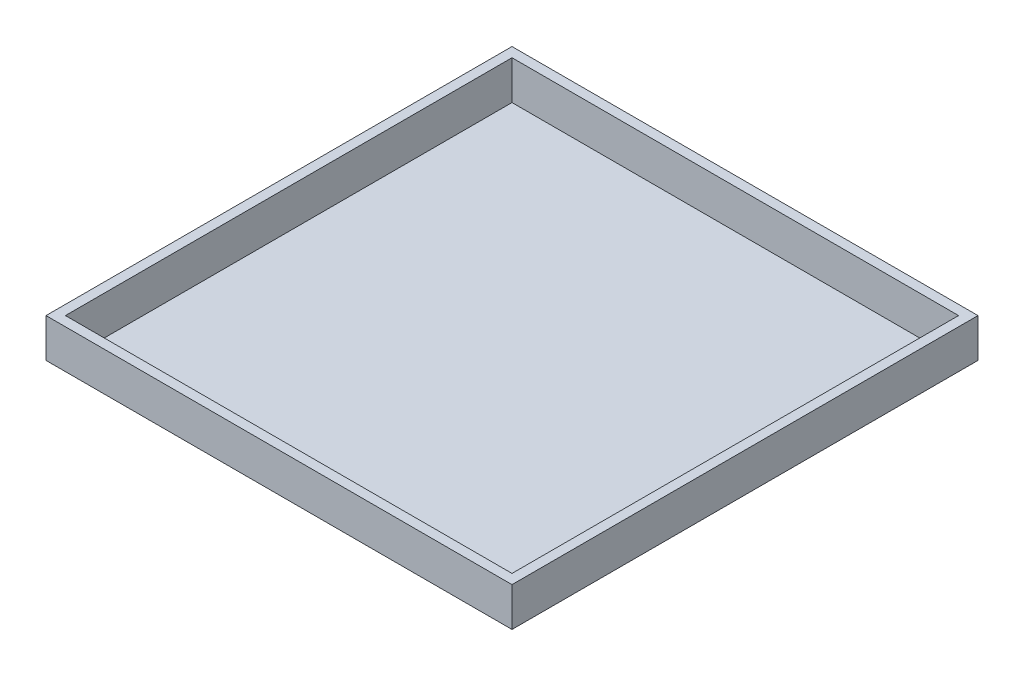
from build123d import *

# Parameters (mm, degrees)
SKETCH1_W           = 2400
SKETCH1_H           = 2400
BOSS_EXTRUDE1_DEPTH = 0.1
SKETCH2_W           = 2400
SKETCH2_H           = 2400
SKETCH2_W_2         = 2300
SKETCH2_H_2         = 2300
BOSS_EXTRUDE3_DEPTH = 200


with BuildPart() as part:
    # Sketch1 → Boss-Extrude1 (new body)
    with BuildSketch(Plane(origin=(0, 0, 0), x_dir=(1, 0, 0), z_dir=(0, 1, 0))):
        with Locations((1200, 1200)):
            Rectangle(SKETCH1_W, SKETCH1_H)
    extrude(amount=BOSS_EXTRUDE1_DEPTH)


with BuildPart() as body_2:
    # Sketch2 → Boss-Extrude3 (new body)
    with BuildSketch(Plane(origin=(0, 0.1, 0), x_dir=(1, 0, 0), z_dir=(0, 1, 0))):
        with Locations((1200, 1200)):
            Rectangle(SKETCH2_W, SKETCH2_H)
        with Locations((1200, 1200)):
            Rectangle(SKETCH2_W_2, SKETCH2_H_2, mode=Mode.SUBTRACT)
    extrude(amount=BOSS_EXTRUDE3_DEPTH)


solid = Compound([part.part, body_2.part])
